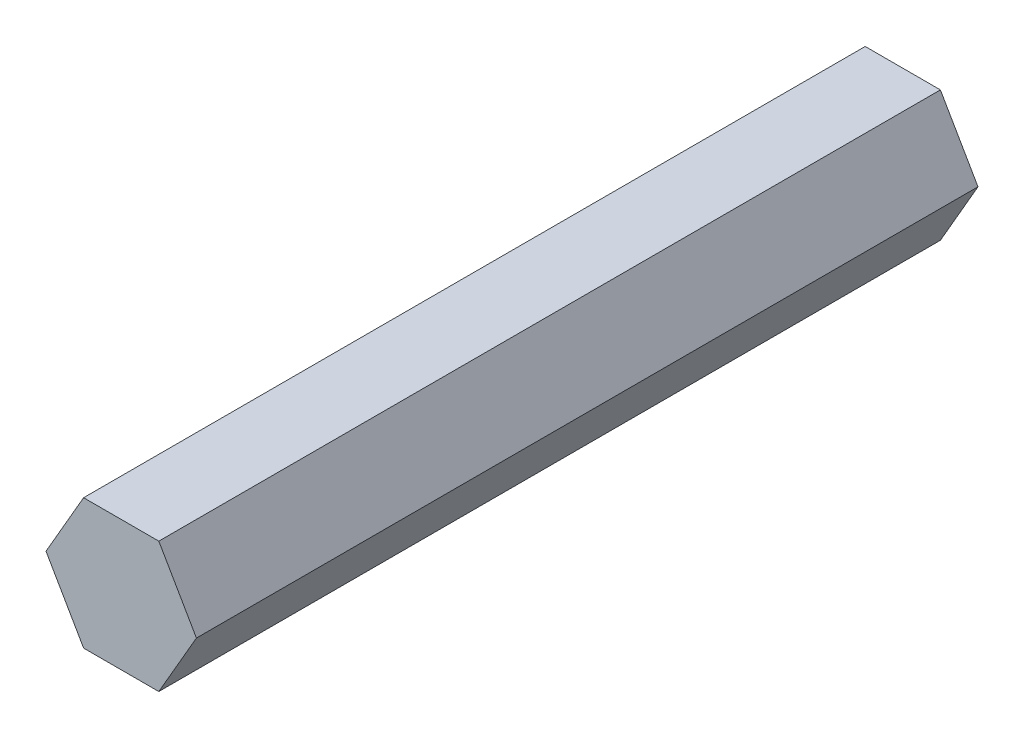
from build123d import *

# Parameters (mm, degrees)
BOSS_EXTRUDE1_DEPTH = 76.2


with BuildPart() as part:
    # Sketch1 → Boss-Extrude1 (new body)
    with BuildSketch(Plane.XY):
        Polygon((7.332348419, 0), (3.666174209, 6.35), (-3.666174209, 6.35), (-7.332348419, 0), (-3.666174209, -6.35), (3.666174209, -6.35), align=None)
    extrude(amount=BOSS_EXTRUDE1_DEPTH)


solid = part.part
